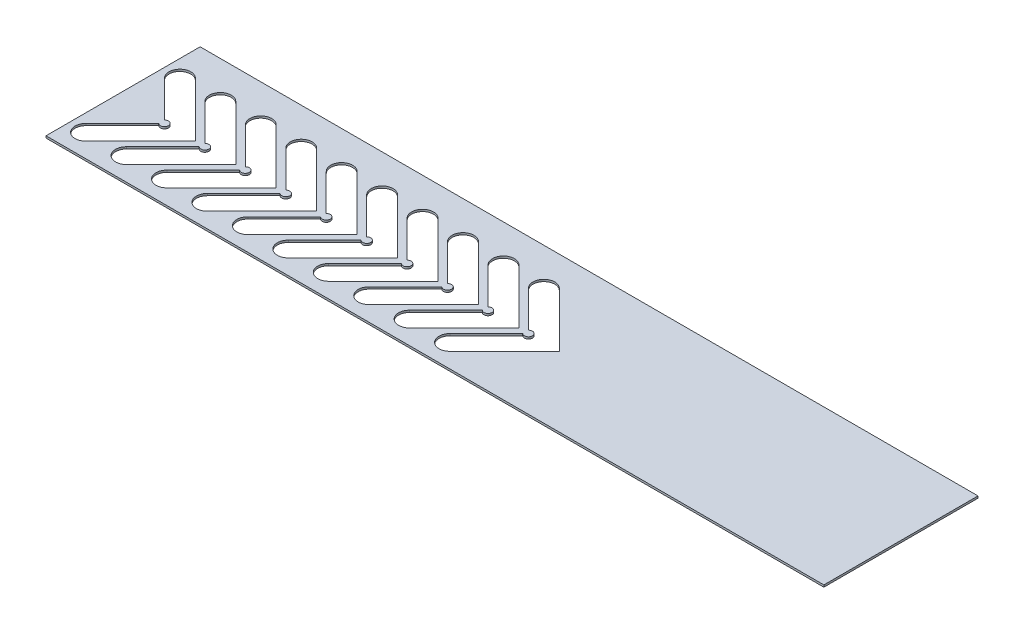
from build123d import *

# Parameters (mm, degrees)
SKETCH1_W           = 192.336493245
SKETCH1_H           = 38.107536872
BOSS_EXTRUDE1_DEPTH = 0.5


with BuildPart() as part:
    # Sketch1 → Boss-Extrude1 (new body)
    with BuildSketch(Plane(origin=(0, 0, 0), x_dir=(1, 0, 0), z_dir=(0, 1, 0))):
        with Locations((76.086163536, 1.75)):
            Rectangle(SKETCH1_W, SKETCH1_H)
        with BuildLine():
            Line((-17.791271396, 9.694580127), (-8.803798051, 0.707106781))
            ThreePointArc((-8.803798051, 0.707106781), (-7.096691269, 0), (-8.803798051, -0.707106781))
            Line((-8.803798051, -0.707106781), (-17.791271396, -9.694580127))
            ThreePointArc((-17.791271396, -9.694580127), (-17.791271396, -13.512956745), (-13.972894778, -13.512956745))
            Line((-13.972894778, -13.512956745), (-0.459938033, 0))
            Line((-0.459938033, 0), (-13.972894778, 13.512956745))
            ThreePointArc((-13.972894778, 13.512956745), (-17.791271396, 13.512956745), (-17.791271396, 9.694580127))
        make_face(mode=Mode.SUBTRACT)
        with BuildLine():
            Line((-3.972894778, 13.512956745), (9.540061967, 0))
            Line((9.540061967, 0), (-3.972894778, -13.512956745))
            ThreePointArc((-3.972894778, -13.512956745), (-7.791271396, -13.512956745), (-7.791271396, -9.694580127))
            Line((-7.791271396, -9.694580127), (1.196201949, -0.707106781))
            ThreePointArc((1.196201949, -0.707106781), (2.903308731, 0), (1.196201949, 0.707106781))
            Line((1.196201949, 0.707106781), (-7.791271396, 9.694580127))
            ThreePointArc((-7.791271396, 9.694580127), (-7.791271396, 13.512956745), (-3.972894778, 13.512956745))
        make_face(mode=Mode.SUBTRACT)
        with BuildLine():
            Line((6.027105222, 13.512956745), (19.540061967, 0))
            Line((19.540061967, 0), (6.027105222, -13.512956745))
            ThreePointArc((6.027105222, -13.512956745), (2.208728604, -13.512956745), (2.208728604, -9.694580127))
            Line((2.208728604, -9.694580127), (11.196201949, -0.707106781))
            ThreePointArc((11.196201949, -0.707106781), (12.903308731, 0), (11.196201949, 0.707106781))
            Line((11.196201949, 0.707106781), (2.208728604, 9.694580127))
            ThreePointArc((2.208728604, 9.694580127), (2.208728604, 13.512956745), (6.027105222, 13.512956745))
        make_face(mode=Mode.SUBTRACT)
        with BuildLine():
            Line((16.027105222, 13.512956745), (29.540061967, 0))
            Line((29.540061967, 0), (16.027105222, -13.512956745))
            ThreePointArc((16.027105222, -13.512956745), (12.208728604, -13.512956745), (12.208728604, -9.694580127))
            Line((12.208728604, -9.694580127), (21.196201949, -0.707106781))
            ThreePointArc((21.196201949, -0.707106781), (22.903308731, 0), (21.196201949, 0.707106781))
            Line((21.196201949, 0.707106781), (12.208728604, 9.694580127))
            ThreePointArc((12.208728604, 9.694580127), (12.208728604, 13.512956745), (16.027105222, 13.512956745))
        make_face(mode=Mode.SUBTRACT)
        with BuildLine():
            Line((26.027105222, 13.512956745), (39.540061967, 0))
            Line((39.540061967, 0), (26.027105222, -13.512956745))
            ThreePointArc((26.027105222, -13.512956745), (22.208728604, -13.512956745), (22.208728604, -9.694580127))
            Line((22.208728604, -9.694580127), (31.196201949, -0.707106781))
            ThreePointArc((31.196201949, -0.707106781), (32.903308731, 0), (31.196201949, 0.707106781))
            Line((31.196201949, 0.707106781), (22.208728604, 9.694580127))
            ThreePointArc((22.208728604, 9.694580127), (22.208728604, 13.512956745), (26.027105222, 13.512956745))
        make_face(mode=Mode.SUBTRACT)
        with BuildLine():
            Line((36.027105222, 13.512956745), (49.540061967, 0))
            Line((49.540061967, 0), (36.027105222, -13.512956745))
            ThreePointArc((36.027105222, -13.512956745), (32.208728604, -13.512956745), (32.208728604, -9.694580127))
            Line((32.208728604, -9.694580127), (41.196201949, -0.707106781))
            ThreePointArc((41.196201949, -0.707106781), (42.903308731, 0), (41.196201949, 0.707106781))
            Line((41.196201949, 0.707106781), (32.208728604, 9.694580127))
            ThreePointArc((32.208728604, 9.694580127), (32.208728604, 13.512956745), (36.027105222, 13.512956745))
        make_face(mode=Mode.SUBTRACT)
        with BuildLine():
            Line((46.027105222, 13.512956745), (59.540061967, 0))
            Line((59.540061967, 0), (46.027105222, -13.512956745))
            ThreePointArc((46.027105222, -13.512956745), (42.208728604, -13.512956745), (42.208728604, -9.694580127))
            Line((42.208728604, -9.694580127), (51.196201949, -0.707106781))
            ThreePointArc((51.196201949, -0.707106781), (52.903308731, 0), (51.196201949, 0.707106781))
            Line((51.196201949, 0.707106781), (42.208728604, 9.694580127))
            ThreePointArc((42.208728604, 9.694580127), (42.208728604, 13.512956745), (46.027105222, 13.512956745))
        make_face(mode=Mode.SUBTRACT)
        with BuildLine():
            Line((56.027105222, 13.512956745), (69.540061967, 0))
            Line((69.540061967, 0), (56.027105222, -13.512956745))
            ThreePointArc((56.027105222, -13.512956745), (52.208728604, -13.512956745), (52.208728604, -9.694580127))
            Line((52.208728604, -9.694580127), (61.196201949, -0.707106781))
            ThreePointArc((61.196201949, -0.707106781), (62.903308731, 0), (61.196201949, 0.707106781))
            Line((61.196201949, 0.707106781), (52.208728604, 9.694580127))
            ThreePointArc((52.208728604, 9.694580127), (52.208728604, 13.512956745), (56.027105222, 13.512956745))
        make_face(mode=Mode.SUBTRACT)
        with BuildLine():
            Line((66.027105222, 13.512956745), (79.540061967, 0))
            Line((79.540061967, 0), (66.027105222, -13.512956745))
            ThreePointArc((66.027105222, -13.512956745), (62.208728604, -13.512956745), (62.208728604, -9.694580127))
            Line((62.208728604, -9.694580127), (71.196201949, -0.707106781))
            ThreePointArc((71.196201949, -0.707106781), (72.903308731, 0), (71.196201949, 0.707106781))
            Line((71.196201949, 0.707106781), (62.208728604, 9.694580127))
            ThreePointArc((62.208728604, 9.694580127), (62.208728604, 13.512956745), (66.027105222, 13.512956745))
        make_face(mode=Mode.SUBTRACT)
        with BuildLine():
            Line((76.027105222, 13.512956745), (89.540061967, 0))
            Line((89.540061967, 0), (76.027105222, -13.512956745))
            ThreePointArc((76.027105222, -13.512956745), (72.208728604, -13.512956745), (72.208728604, -9.694580127))
            Line((72.208728604, -9.694580127), (81.196201949, -0.707106781))
            ThreePointArc((81.196201949, -0.707106781), (82.903308731, 0), (81.196201949, 0.707106781))
            Line((81.196201949, 0.707106781), (72.208728604, 9.694580127))
            ThreePointArc((72.208728604, 9.694580127), (72.208728604, 13.512956745), (76.027105222, 13.512956745))
        make_face(mode=Mode.SUBTRACT)
    extrude(amount=BOSS_EXTRUDE1_DEPTH)


solid = part.part
